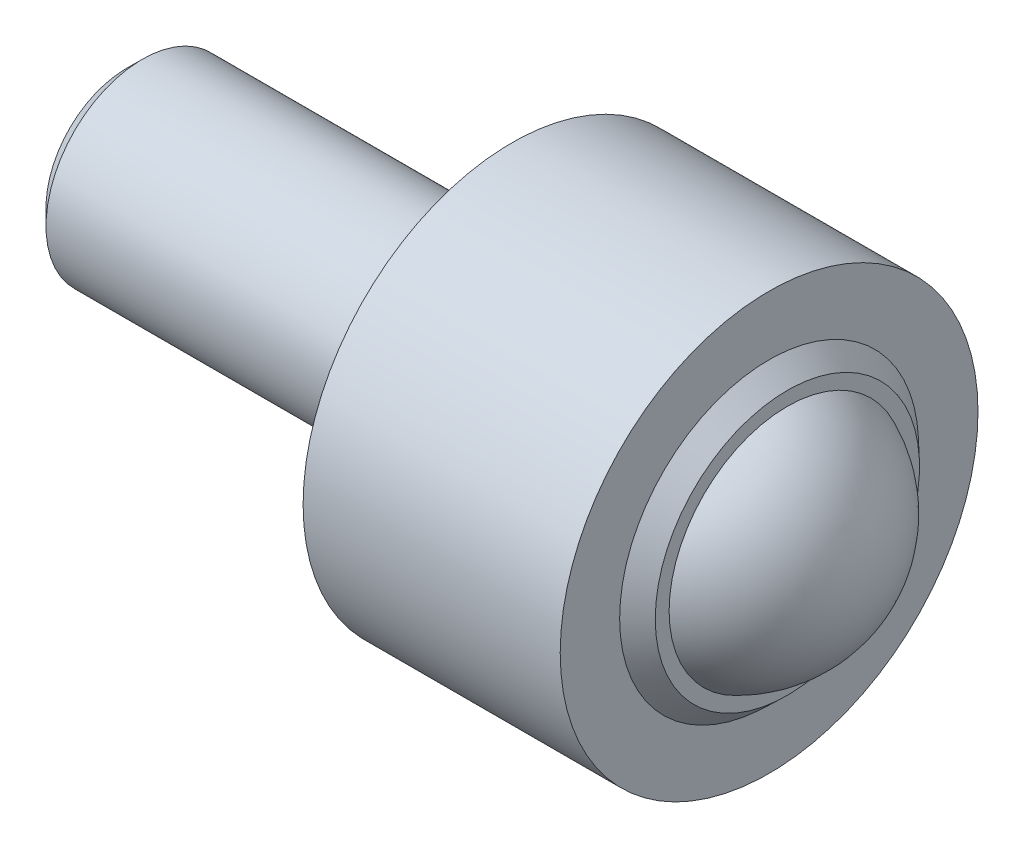
from build123d import *

# Parameters (mm, degrees)
SKETCH_1_R      = 3
EXTRUDE_1_DEPTH = 12
SKETCH_2_R      = 6.5
EXTRUDE_2_DEPTH = 8
CHAMFER_1_SIZE  = 0.5


with BuildPart() as part:
    # 草图1 → 凸台-拉伸1 (new body)
    with BuildSketch(Plane(origin=(0, 0, 0), x_dir=(0, 0, -1), z_dir=(1, 0, 0))):
        Circle(SKETCH_1_R)
    extrude(amount=EXTRUDE_1_DEPTH)

    # 草图2 → 凸台-拉伸2 (add)
    with BuildSketch(Plane(origin=(12, 0, 0), x_dir=(0, 0, -1), z_dir=(1, 0, 0))):
        Circle(SKETCH_2_R)
    extrude(amount=EXTRUDE_2_DEPTH)

    # 草图3 → 旋转2 (revolve)
    with BuildSketch(Plane(origin=(0, 0, 0), x_dir=(1, 0, 0), z_dir=(0, 1, 0))):
        with BuildLine():
            Line((15, 0), (23, 0))
            ThreePointArc((23, 0), (22.337104701, 2.20538709), (20.568133892, 3.679803812))
            Line((20.568133892, 3.679803812), (20.568133892, 4.110994158))
            Line((20.568133892, 4.110994158), (20, 4.650865374))
            Line((20, 4.650865374), (20, 3.872983346))
            ThreePointArc((20, 3.872983346), (16.550510257, 3.16227766), (15, 0))
        make_face()
    revolve(axis=Axis((15, 0, 0), (1, 0, 0)))

    # 倒角1
    chamfer_1_edges = [part.edges().sort_by_distance(p)[0] for p in [
        (0, 0, 3),
    ]]
    chamfer(chamfer_1_edges, length=CHAMFER_1_SIZE)


solid = part.part
